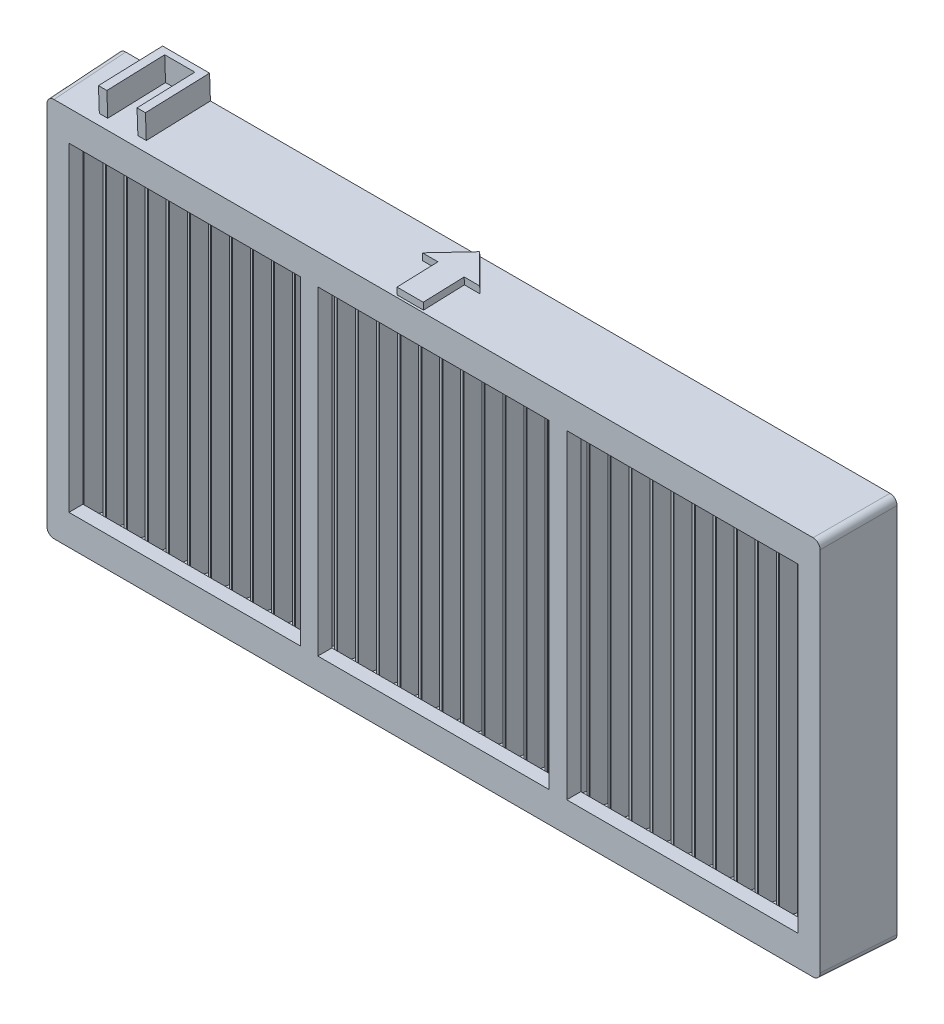
from build123d import *

# Parameters (mm, degrees)
SKETCH1_W               = 111
SKETCH1_H               = 55
BOSS_EXTRUDE1_DEPTH     = 10.6
BOSS_EXTRUDE1_TAPER     = 2
SHELL1_T                = 2
SKETCH3_W               = 32
SKETCH3_H               = 22
SKETCH3_H_2             = 22.3
SKETCH3_W_2             = 34.8
FILTERCUTOUTBACK_DEPTH  = 2
SKETCH4_W               = 33
SKETCH4_H               = 45.6
FILTERCUTOUTFRONT_DEPTH = 2
FILLET1_R               = 1
TAB_DEPTH               = 3.5
DIRECTIONARROW_DEPTH    = 1
INTERNALFILTER_DEPTH    = 0.2
BOSS_EXTRUDE6_REACH     = 2982.639
BOSS_EXTRUDE6_START     = 3
LPATTERN1_COUNT         = 35
LPATTERN1_PITCH         = 3
BOSS_EXTRUDE5_REACH     = 2979.639


with BuildPart() as part:
    # Sketch1 → Boss-Extrude1 (new body)
    with BuildSketch(Plane.XY):
        with Locations((55.5, 27.5)):
            Rectangle(SKETCH1_W, SKETCH1_H)
    extrude(amount=BOSS_EXTRUDE1_DEPTH, taper=BOSS_EXTRUDE1_TAPER)

    # Shell1 (no face opened: a closed hollow body)
    add(offset(amount=-SHELL1_T, mode=Mode.PRIVATE), mode=Mode.SUBTRACT)

    # Sketch3 → FilterCutoutBack (cut)
    with BuildSketch(Plane(origin=(0, 0, 0), x_dir=(-1, 0, 0), z_dir=(0, 0, -1))):
        with Locations((-90.4, 39.4)):
            Rectangle(SKETCH3_W, SKETCH3_H)
        with Locations((-90.4, 15.75)):
            Rectangle(SKETCH3_W, SKETCH3_H_2)
        with Locations((-55.5, 39.4)):
            Rectangle(SKETCH3_W_2, SKETCH3_H)
        with Locations((-20.6, 39.4)):
            Rectangle(SKETCH3_W, SKETCH3_H)
        with Locations((-55.5, 15.75)):
            Rectangle(SKETCH3_W_2, SKETCH3_H_2)
        with Locations((-20.6, 15.75)):
            Rectangle(SKETCH3_W, SKETCH3_H_2)
    extrude(amount=-FILTERCUTOUTBACK_DEPTH, mode=Mode.SUBTRACT)

    # Sketch4 → FilterCutoutFront (cut)
    with BuildSketch(Plane.XY.offset(10.6)):
        with Locations((20, 27.5)):
            Rectangle(SKETCH4_W, SKETCH4_H)
        with Locations((55.5, 27.5)):
            Rectangle(SKETCH4_W, SKETCH4_H)
        with Locations((91, 27.5)):
            Rectangle(SKETCH4_W, SKETCH4_H)
    extrude(amount=-FILTERCUTOUTFRONT_DEPTH, mode=Mode.SUBTRACT)

    # Fillet1
    fillet1_edges = [part.edges().sort_by_distance(p)[0] for p in [
        (0.185080078, 54.814919922, 5.3),
        (110.814919922, 54.814919922, 5.3),
        (110.814919922, 0.185080078, 5.3),
        (0.185080078, 0.185080078, 5.3),
    ]]
    fillet(fillet1_edges, radius=FILLET1_R)

    # Sketch5 → TAB (add)
    with BuildSketch(Plane(origin=(0, 54.933011382, 1.918303028), x_dir=(1, 0, 0), z_dir=(0, 0.9993908270190958, 0.03489949670250101))):
        Polygon((13.08, -7.230527681), (13.08, 1.919472319), (6.38, 1.919472319), (6.38, -7.230527681), (7.58, -7.230527681), (7.58, 1.019472319), (11.88, 1.019472319), (11.88, -7.230527681), align=None)
    extrude(amount=TAB_DEPTH)

    # Sketch6 → DirectionArrow (add)
    with BuildSketch(Plane(origin=(0, 54.933011382, 1.918303028), x_dir=(1, 0, 0), z_dir=(0, 0.9993908270190958, 0.03489949670250101))):
        Polygon((47.799081744, -2.533690102), (51.883425318, 1.550653472), (55.967768891, -2.533690102), (53.753860362, -2.533690102), (53.753860362, -8.373718505), (50.012990273, -8.373718505), (50.012990273, -2.533690102), align=None)
    extrude(amount=DIRECTIONARROW_DEPTH)

    # Sketch7 → InternalFilter (add)
    with BuildSketch(Plane(origin=(0, 0, 2974.994420517), x_dir=(-1, 0, 0), z_dir=(0, 1, 0))):
        Polygon((-108.448462294, -2966.394420517), (-107.271559358, -2972.744420517), (-105.629337698, -2966.394420517), (-105.379337698, -2966.394420517), (-107.086213755, -2972.994420517), (-107.475224597, -2972.994420517), (-108.698462294, -2966.394420517), align=None)
    extrude(amount=INTERNALFILTER_DEPTH)

    # Boss-Extrude6: up to this face of the body (flat: up to its plane)
    boss_extrude6_end = Plane(part.part.faces().sort_by_distance((55.5, 52.813783863, 5.29762233))[0])
    # Sketch7_3 → Boss-Extrude6 (add, up to the picked face)
    with BuildSketch(Plane(origin=(0, 0, 2974.994420517), x_dir=(-1, 0, 0), z_dir=(0, 1, 0)).offset(BOSS_EXTRUDE6_START), mode=Mode.PRIVATE) as boss_extrude6_sk1:
        Polygon((-108.448462294, -2966.394420517), (-107.271559358, -2972.744420517), (-105.629337698, -2966.394420517), (-105.379337698, -2966.394420517), (-107.086213755, -2972.994420517), (-107.475224597, -2972.994420517), (-108.698462294, -2966.394420517), align=None)
    boss_extrude6_tool1 = split(extrude(boss_extrude6_sk1.sketch, amount=BOSS_EXTRUDE6_REACH, mode=Mode.PRIVATE), bisect_by=boss_extrude6_end, keep=Keep.BOTH, mode=Mode.PRIVATE)
    boss_extrude6 = boss_extrude6_tool1.solids().sort_by(Axis((107.93265, 3, 5.411537), (0, 1, 0)))[0]
    add(boss_extrude6)

    # LPattern1: Boss-Extrude6 ×35
    with Locations(*[(-i * LPATTERN1_PITCH, 0, 0) for i in range(1, LPATTERN1_COUNT)]):
        add(boss_extrude6)

    # Boss-Extrude5: up to this face of the body (flat: up to its plane)
    boss_extrude5_end = Plane(part.part.faces().sort_by_distance((55.5, 2.186216137, 5.29762233))[0])
    # Sketch7_2 → Boss-Extrude5 (add, up to the picked face)
    with BuildSketch(Plane(origin=(0, 0, 2974.994420517), x_dir=(-1, 0, 0), z_dir=(0, 1, 0)), mode=Mode.PRIVATE) as boss_extrude5_sk1:
        Polygon((-108.448462294, -2966.394420517), (-107.271559358, -2972.744420517), (-105.629337698, -2966.394420517), (-105.379337698, -2966.394420517), (-107.086213755, -2972.994420517), (-107.475224597, -2972.994420517), (-108.698462294, -2966.394420517), align=None)
    boss_extrude5_tool1 = split(extrude(boss_extrude5_sk1.sketch, amount=BOSS_EXTRUDE5_REACH, mode=Mode.PRIVATE), bisect_by=boss_extrude5_end, keep=Keep.BOTH, mode=Mode.PRIVATE)
    add(boss_extrude5_tool1.solids().sort_by(Axis((107.93265, 0, 5.411537), (0, 1, 0)))[0])


solid = part.part
